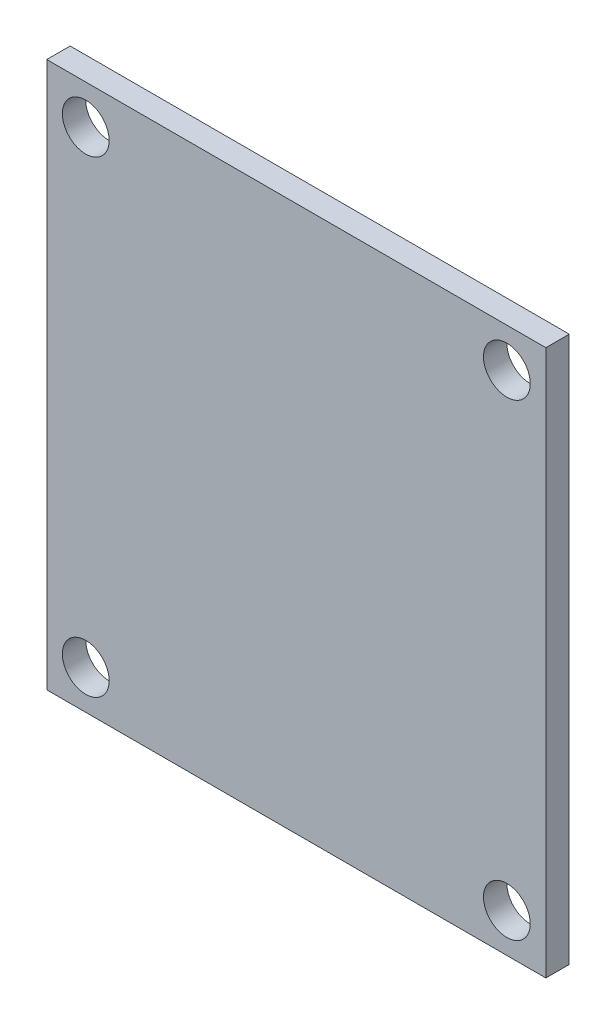
from build123d import *

# Parameters (mm, degrees)
SKETCH_1_W      = 32
SKETCH_1_H      = 35
SKETCH_1_R      = 1.5
EXTRUDE_1_DEPTH = 1.5


with BuildPart() as part:
    # Эскиз1 → Бобышка-Вытянуть1 (new body)
    with BuildSketch(Plane.XY):
        with Locations((16, 17.5)):
            Rectangle(SKETCH_1_W, SKETCH_1_H)
        with Locations((2.5, 32.5)):
            Circle(SKETCH_1_R, mode=Mode.SUBTRACT)
        with Locations((29.5, 32.5)):
            Circle(SKETCH_1_R, mode=Mode.SUBTRACT)
        with Locations((29.5, 2.5)):
            Circle(SKETCH_1_R, mode=Mode.SUBTRACT)
        with Locations((2.5, 2.5)):
            Circle(SKETCH_1_R, mode=Mode.SUBTRACT)
    extrude(amount=EXTRUDE_1_DEPTH)


solid = part.part
